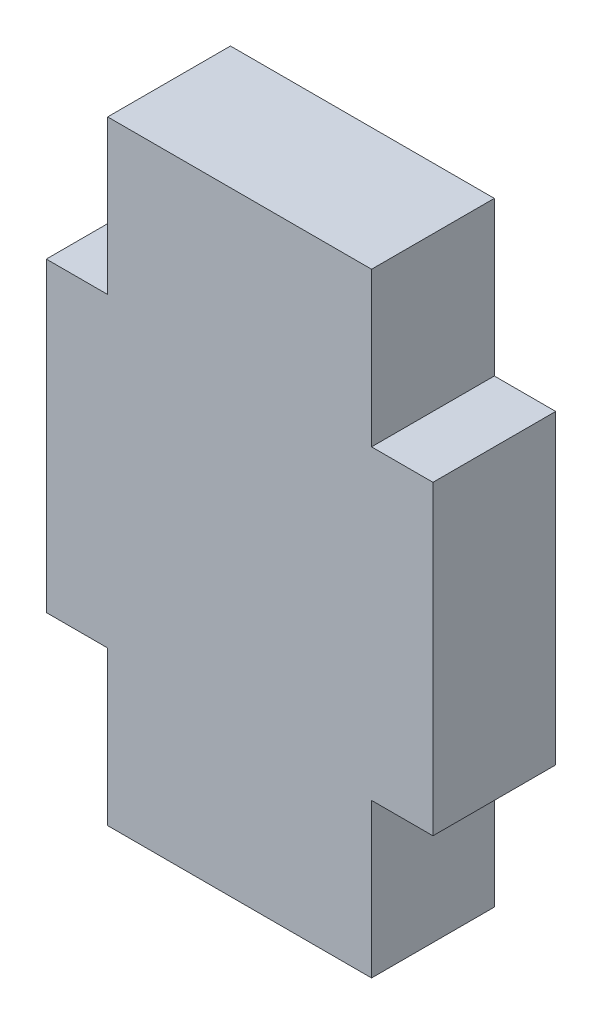
from build123d import *

# Parameters (mm, degrees)
BOSS_EXTRUDE1_DEPTH = 5.08


with BuildPart() as part:
    # Sketch1 → Boss-Extrude1 (new body)
    with BuildSketch(Plane.XY):
        Polygon((-17.524, 73.641491945), (-6.604, 73.641491945), (-6.604, 80.007094601), (-4.064, 80.007094601), (-4.064, 92.675889289), (-6.604, 92.675889289), (-6.604, 99.041491945), (-17.524, 99.041491945), (-17.524, 92.675889289), (-20.064, 92.675889289), (-20.064, 80.007094601), (-17.524, 80.007094601), align=None)
    extrude(amount=BOSS_EXTRUDE1_DEPTH)


solid = part.part
